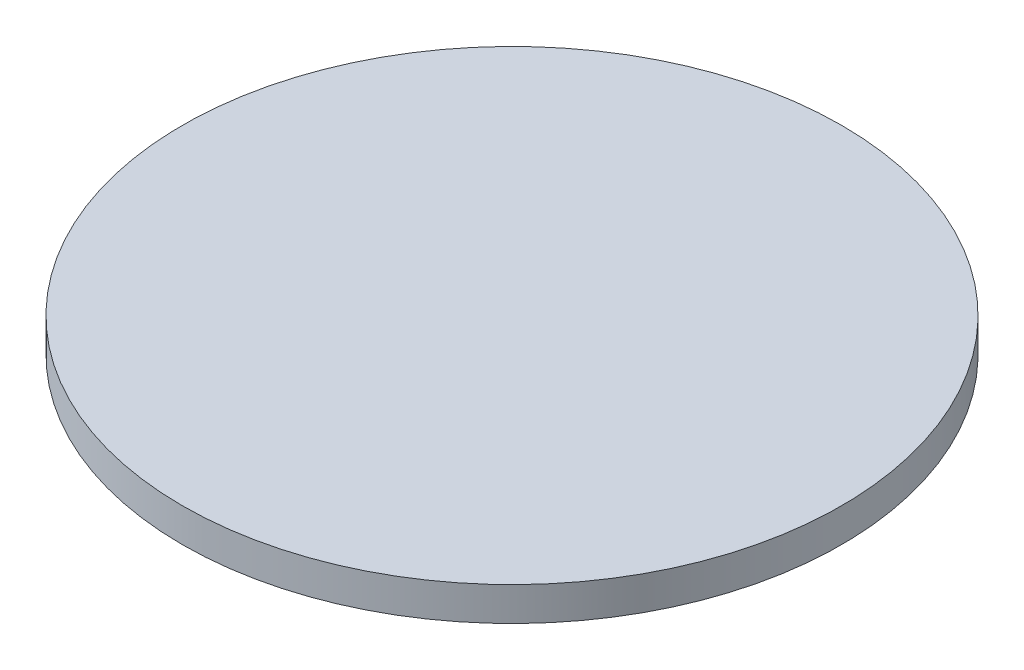
from build123d import *

# Parameters (mm, degrees)
ESQUISSE1_R        = 21.5
BOSS_EXTRU_1_DEPTH = 2.2


with BuildPart() as part:
    # Esquisse1 → Boss.-Extru.1 (new body)
    with BuildSketch(Plane(origin=(0, 0, 0), x_dir=(1, 0, 0), z_dir=(0, 1, 0))):
        Circle(ESQUISSE1_R)
    extrude(amount=BOSS_EXTRU_1_DEPTH)


solid = part.part
